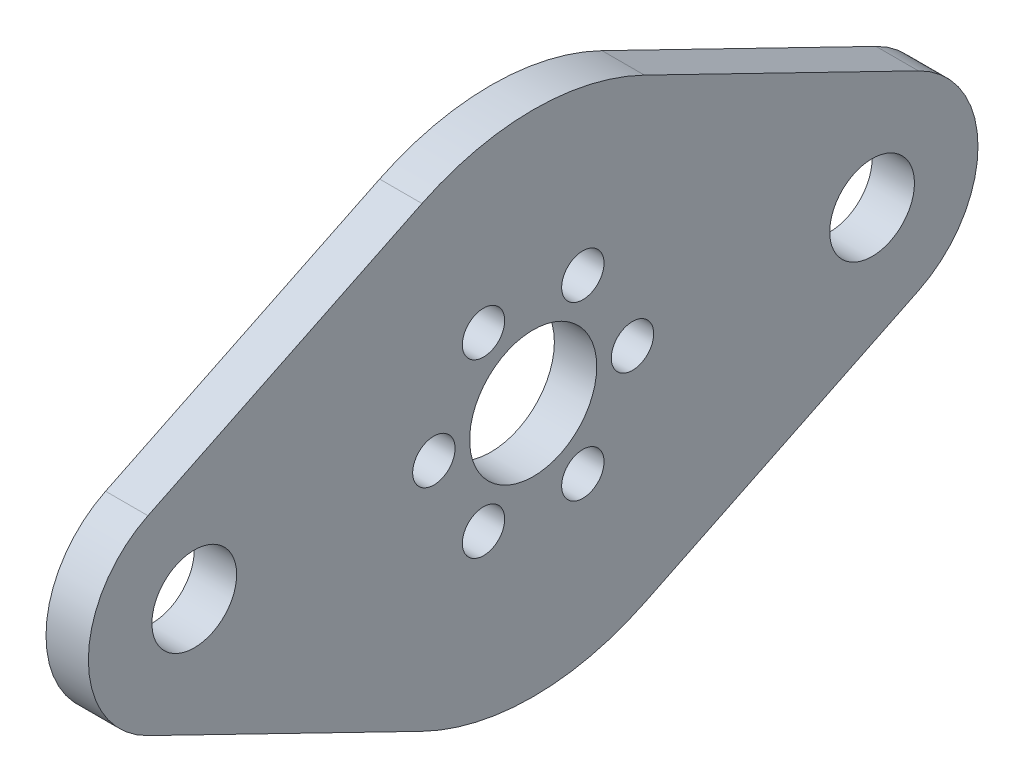
from build123d import *

# Parameters (mm, degrees)
SKETCH1_R           = 4.7625
SKETCH1_R_2         = 3.175
SKETCH1_R_3         = 1.5875
BOSS_EXTRUDE1_DEPTH = 3.175


with BuildPart() as part:
    # Sketch1 → Boss-Extrude1 (new body)
    with BuildSketch(Plane(origin=(0, 0, 0), x_dir=(0, 0, -1), z_dir=(1, 0, 0))):
        with BuildLine():
            Line((-28.87265625, 7.137546134), (-8.334375, 17.130110722))
            ThreePointArc((-8.334375, 17.130110722), (0, 19.05), (8.334375, 17.130110722))
            Line((8.334375, 17.130110722), (28.87265625, 7.137546134))
            ThreePointArc((28.87265625, 7.137546134), (33.3375, 0), (28.87265625, -7.137546134))
            Line((28.87265625, -7.137546134), (8.334375, -17.130110722))
            ThreePointArc((8.334375, -17.130110722), (0, -19.05), (-8.334375, -17.130110722))
            Line((-8.334375, -17.130110722), (-28.87265625, -7.137546134))
            ThreePointArc((-28.87265625, -7.137546134), (-33.3375, 0), (-28.87265625, 7.137546134))
        make_face()
        Circle(SKETCH1_R, mode=Mode.SUBTRACT)
        with Locations((-25.4, 0)):
            Circle(SKETCH1_R_2, mode=Mode.SUBTRACT)
        with Locations((25.4, 0)):
            Circle(SKETCH1_R_2, mode=Mode.SUBTRACT)
        with Locations((-3.7211, -6.44513426)):
            Circle(SKETCH1_R_3, mode=Mode.SUBTRACT)
        with Locations((3.7211, 6.44513426)):
            Circle(SKETCH1_R_3, mode=Mode.SUBTRACT)
        with Locations((3.7211, -6.44513426)):
            Circle(SKETCH1_R_3, mode=Mode.SUBTRACT)
        with Locations((-3.7211, 6.44513426)):
            Circle(SKETCH1_R_3, mode=Mode.SUBTRACT)
        with Locations((-7.4422, 0)):
            Circle(SKETCH1_R_3, mode=Mode.SUBTRACT)
        with Locations((7.4422, 0)):
            Circle(SKETCH1_R_3, mode=Mode.SUBTRACT)
    extrude(amount=BOSS_EXTRUDE1_DEPTH)


solid = part.part
